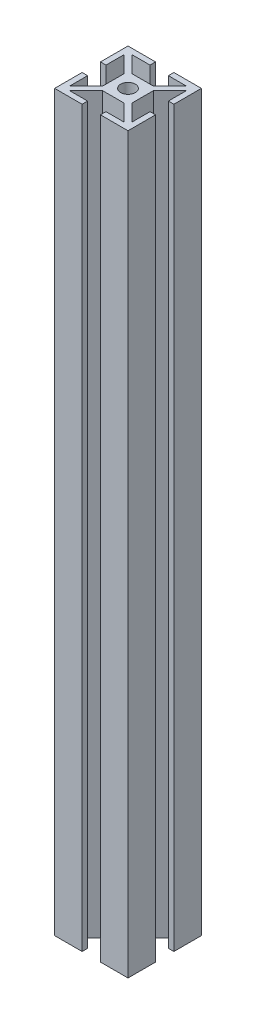
from build123d import *

# Parameters (mm, degrees)
DODANIE_WYCI_GNI_CIE1_DEPTH = 200


with BuildPart() as part:
    # Szkic1 → Dodanie-wyciągnięcie1 (new body)
    with BuildSketch(Plane(origin=(0, 0, 0), x_dir=(1, 0, 0), z_dir=(0, 1, 0))):
        Polygon((9.560660172, 8.5), (8.5, 7.439339828), (8.5, 2.5), (10, 2.5), (10, 8.5), align=None)
        Polygon((-8.5, 9.560660172), (-7.439339828, 8.5), (-2.5, 8.5), (-2.5, 10), (-8.5, 10), align=None)
        Polygon((-8.939339828, 10), (-8.5, 9.560660172), (-8.5, 10), align=None)
        Polygon((-10, 10), (-10, 8.939339828), (-9.560660172, 8.5), (-8.5, 8.5), (-8.5, 9.560660172), (-8.939339828, 10), align=None)
        Polygon((-10, 8.939339828), (-10, 8.5), (-9.560660172, 8.5), align=None)
        Polygon((-10, 8.5), (-10, 2.5), (-8.5, 2.5), (-8.5, 7.439339828), (-9.560660172, 8.5), align=None)
        Polygon((-9.560660172, 8.5), (-8.5, 7.439339828), (-8.5, 8.5), align=None)
        Polygon((-8.5, 9.560660172), (-8.5, 8.5), (-7.439339828, 8.5), align=None)
        Polygon((-8.5, 7.439339828), (-4, 2.939339828), (-4, 4), (-2.939339828, 4), (-7.439339828, 8.5), (-8.5, 8.5), align=None)
        Polygon((-10, -10), (-8.939339828, -10), (-8.5, -9.560660172), (-8.5, -8.5), (-9.560660172, -8.5), (-10, -8.939339828), align=None)
        Polygon((-10, -8.5), (-10, -8.939339828), (-9.560660172, -8.5), align=None)
        Polygon((-10, -2.5), (-10, -8.5), (-9.560660172, -8.5), (-8.5, -7.439339828), (-8.5, -2.5), align=None)
        Polygon((-9.560660172, -8.5), (-8.5, -8.5), (-8.5, -7.439339828), align=None)
        Polygon((-8.5, -8.5), (-8.5, -9.560660172), (-7.439339828, -8.5), align=None)
        Polygon((-8.5, -9.560660172), (-8.939339828, -10), (-8.5, -10), align=None)
        Polygon((-7.439339828, -8.5), (-8.5, -9.560660172), (-8.5, -10), (-2.5, -10), (-2.5, -8.5), align=None)
        Polygon((-8.5, -8.5), (-7.439339828, -8.5), (-2.939339828, -4), (-4, -4), (-4, -2.939339828), (-8.5, -7.439339828), align=None)
        with BuildLine():
            Line((-2.939339828, 4), (-0.780680974, 1.841341146))
            ThreePointArc((-0.780680974, 1.841341146), (0, 2), (0.780680974, 1.841341146))
            Line((0.780680974, 1.841341146), (2.939339828, 4))
            Line((2.939339828, 4), (-2.939339828, 4))
        make_face()
        with BuildLine():
            Line((-4, 4), (-4, 2.939339828))
            Line((-4, 2.939339828), (-1.841341146, 0.780680974))
            ThreePointArc((-1.841341146, 0.780680974), (-1.414213562, 1.414213562), (-0.780680974, 1.841341146))
            Line((-0.780680974, 1.841341146), (-2.939339828, 4))
            Line((-2.939339828, 4), (-4, 4))
        make_face()
        with BuildLine():
            Line((-4, 2.939339828), (-4, -2.939339828))
            Line((-4, -2.939339828), (-1.841341146, -0.780680974))
            ThreePointArc((-1.841341146, -0.780680974), (-2, 0), (-1.841341146, 0.780680974))
            Line((-1.841341146, 0.780680974), (-4, 2.939339828))
        make_face()
        with BuildLine():
            Line((-4, -4), (-2.939339828, -4))
            Line((-2.939339828, -4), (-0.780680974, -1.841341146))
            ThreePointArc((-0.780680974, -1.841341146), (-1.414213562, -1.414213562), (-1.841341146, -0.780680974))
            Line((-1.841341146, -0.780680974), (-4, -2.939339828))
            Line((-4, -2.939339828), (-4, -4))
        make_face()
        with BuildLine():
            Line((-0.780680974, -1.841341146), (-2.939339828, -4))
            Line((-2.939339828, -4), (2.939339828, -4))
            Line((2.939339828, -4), (0.780680974, -1.841341146))
            ThreePointArc((0.780680974, -1.841341146), (0, -2), (-0.780680974, -1.841341146))
        make_face()
        with BuildLine():
            Line((0.780680974, -1.841341146), (2.939339828, -4))
            Line((2.939339828, -4), (4, -4))
            Line((4, -4), (4, -2.939339828))
            Line((4, -2.939339828), (1.841341146, -0.780680974))
            ThreePointArc((1.841341146, -0.780680974), (1.414213562, -1.414213562), (0.780680974, -1.841341146))
        make_face()
        with BuildLine():
            ThreePointArc((2, 0), (1.959933965, -0.39832004), (1.841341146, -0.780680974))
            Line((1.841341146, -0.780680974), (4, -2.939339828))
            Line((4, -2.939339828), (4, 2.939339828))
            Line((4, 2.939339828), (1.841341146, 0.780680974))
            ThreePointArc((1.841341146, 0.780680974), (1.959933965, 0.39832004), (2, 0))
        make_face()
        with BuildLine():
            ThreePointArc((0.780680974, 1.841341146), (1.414213562, 1.414213562), (1.841341146, 0.780680974))
            Line((1.841341146, 0.780680974), (4, 2.939339828))
            Line((4, 2.939339828), (4, 4))
            Line((4, 4), (2.939339828, 4))
            Line((2.939339828, 4), (0.780680974, 1.841341146))
        make_face()
        Polygon((2.5, 8.5), (7.439339828, 8.5), (8.5, 9.560660172), (8.5, 10), (2.5, 10), align=None)
        Polygon((7.439339828, 8.5), (8.5, 8.5), (8.5, 9.560660172), align=None)
        Polygon((8.5, 10), (8.5, 9.560660172), (8.939339828, 10), align=None)
        Polygon((8.5, 8.5), (9.560660172, 8.5), (10, 8.939339828), (10, 10), (8.939339828, 10), (8.5, 9.560660172), align=None)
        Polygon((8.5, 8.5), (8.5, 7.439339828), (9.560660172, 8.5), align=None)
        Polygon((10, 8.939339828), (9.560660172, 8.5), (10, 8.5), align=None)
        Polygon((4, 4), (4, 2.939339828), (8.5, 7.439339828), (8.5, 8.5), (7.439339828, 8.5), (2.939339828, 4), align=None)
        Polygon((4, -4), (2.939339828, -4), (7.439339828, -8.5), (8.5, -8.5), (8.5, -7.439339828), (4, -2.939339828), align=None)
        Polygon((8.5, -8.5), (7.439339828, -8.5), (8.5, -9.560660172), align=None)
        Polygon((8.5, -7.439339828), (8.5, -8.5), (9.560660172, -8.5), align=None)
        Polygon((8.5, -2.5), (8.5, -7.439339828), (9.560660172, -8.5), (10, -8.5), (10, -2.5), align=None)
        Polygon((2.5, -8.5), (2.5, -10), (8.5, -10), (8.5, -9.560660172), (7.439339828, -8.5), align=None)
        Polygon((8.5, -9.560660172), (8.939339828, -10), (10, -10), (10, -8.939339828), (9.560660172, -8.5), (8.5, -8.5), align=None)
        Polygon((8.5, -9.560660172), (8.5, -10), (8.939339828, -10), align=None)
        Polygon((10, -8.5), (9.560660172, -8.5), (10, -8.939339828), align=None)
    extrude(amount=DODANIE_WYCI_GNI_CIE1_DEPTH)


solid = part.part
